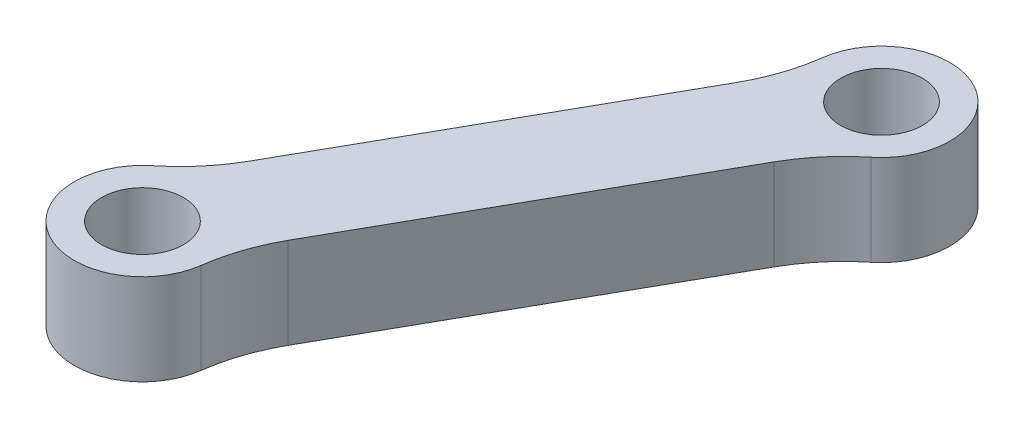
from build123d import *

# Parameters (mm, degrees)
SKETCH1_R           = 2.25
BOSS_EXTRUDE1_DEPTH = 5


with BuildPart() as part:
    # Sketch1 → Boss-Extrude1 (new body)
    with BuildSketch(Plane.XZ.offset(63)):
        with BuildLine():
            Line((8.181928414, -16.605718064), (17.802171103, -33.691169181))
            ThreePointArc((17.802171103, -33.691169181), (18.572370652, -35.426303597), (19.000782012, -37.275725803))
            ThreePointArc((19.000782012, -37.275725803), (24.55776359, -40.047666423), (25.069213931, -33.85879596))
            ThreePointArc((25.069213931, -33.85879596), (23.710027, -32.533462163), (22.625796475, -30.975148024))
            Line((22.625796475, -30.975148024), (13.005553786, -13.889696907))
            ThreePointArc((13.005553786, -13.889696907), (12.235354237, -12.15456249), (11.806942877, -10.305140285))
            ThreePointArc((11.806942877, -10.305140285), (6.249961299, -7.533199664), (5.738510958, -13.722070128))
            ThreePointArc((5.738510958, -13.722070128), (7.097697889, -15.047403925), (8.181928414, -16.605718064))
        make_face()
        with Locations((22.71787829, -36.780049236)):
            Circle(SKETCH1_R, mode=Mode.SUBTRACT)
        with Locations((8.089846599, -10.800816852)):
            Circle(SKETCH1_R, mode=Mode.SUBTRACT)
    extrude(amount=-BOSS_EXTRUDE1_DEPTH)


solid = part.part
